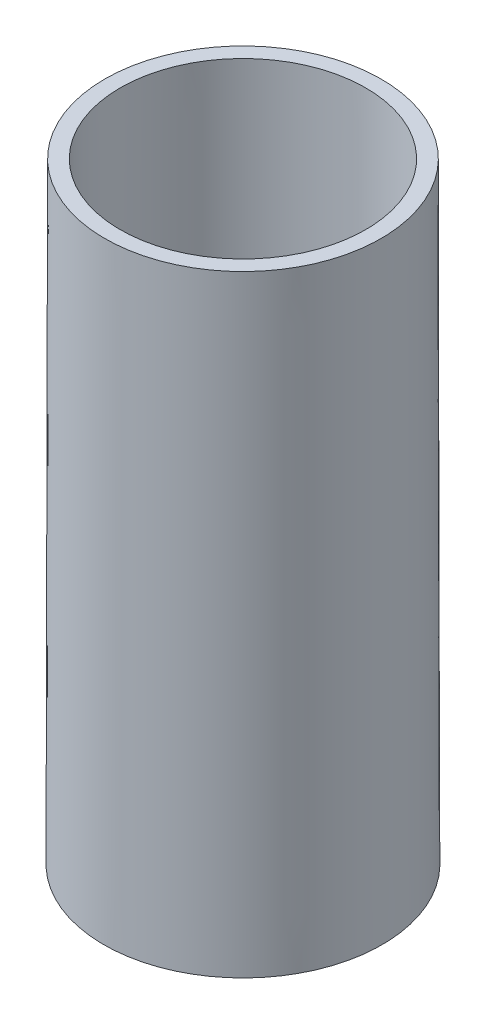
from build123d import *

# Parameters (mm, degrees)
SKETCH2_R          = 88.424211621
CUT_EXTRUDE1_DEPTH = 99


with BuildPart() as part:
    # Sketch1 → Revolve1 (revolve)
    with BuildSketch(Plane.XY):
        Polygon((0, 0), (49.435, 0), (50, -318.391407512), (44.484296437, -318.391407512), (43.930100232, -6.088204487), (0, -6.088204487), align=None)
    revolve(axis=Axis((0, 0, 0), (0, -1, 0)))

    # Sketch2 → Cut-Extrude1 (cut)
    with BuildSketch(Plane(origin=(0, 0, 0), x_dir=(1, 0, 0), z_dir=(0, 1, 0))):
        Circle(SKETCH2_R)
    extrude(amount=-CUT_EXTRUDE1_DEPTH, mode=Mode.SUBTRACT)


solid = part.part
